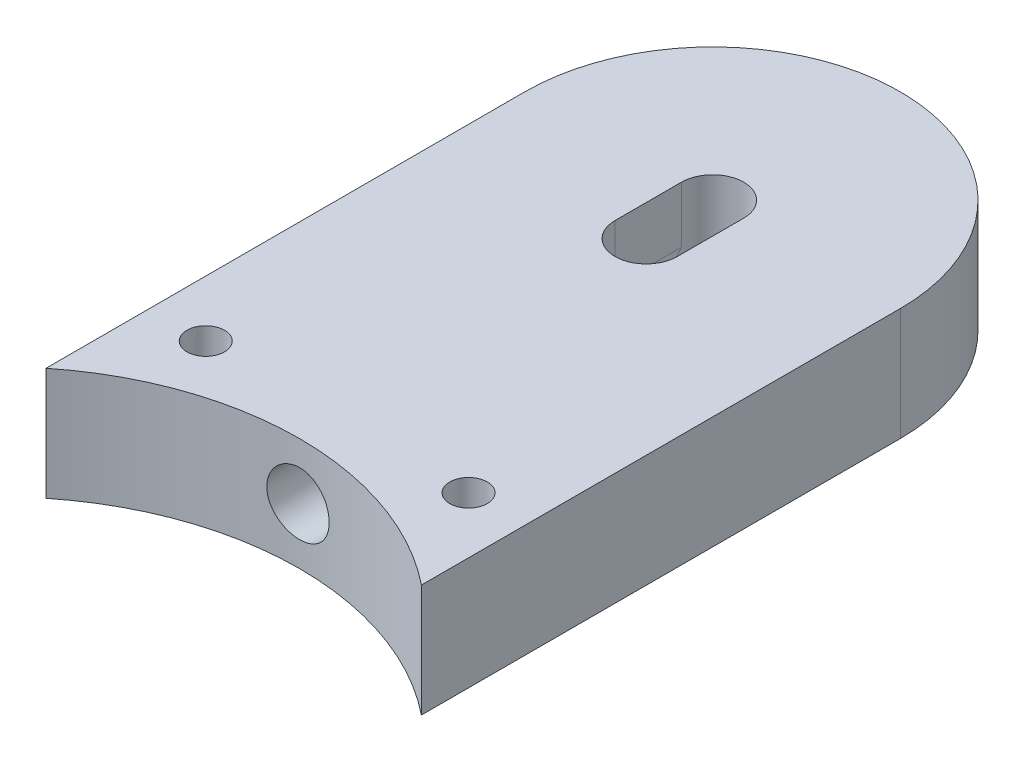
from build123d import *

# Parameters (mm, degrees)
ESQUISSE1_R                  = 4.15
BOSS_EXTRU_1_DEPTH           = 15
ENL_V_MAT_EXTRU_1_REACH      = 122
ENL_V_MAT_EXTRU_1_END_RADIUS = 4.15
ESQUISSE2_R                  = 4.15
ENL_V_MAT_EXTRU_2_DEPTH      = 7.5
TROU_TARAUD_M6X1_01_D        = 5


with BuildPart() as part:
    # Esquisse1 → Boss.-Extru.1 (new body)
    with BuildSketch(Plane(origin=(0, 0, 0), x_dir=(1, 0, 0), z_dir=(0, 1, 0))):
        with BuildLine():
            Line((25, 31.224989992), (25, 95))
            ThreePointArc((25, 95), (0, 120), (-25, 95))
            Line((-25, 95), (-25, 31.224989992))
            ThreePointArc((-25, 31.224989992), (0, 40), (25, 31.224989992))
        make_face()
        with Locations(Location((0, 95, 0), (0, 0, 270))):  # turned: the seam where the file's is
            Circle(ESQUISSE1_R, mode=Mode.SUBTRACT)
    extrude(amount=BOSS_EXTRU_1_DEPTH)

    # Enlèv. mat.-Extru.1: up to this cylinder (the profile starts outside it)
    enl_v_mat_extru_1_end = Plane(origin=(0, 7.5, -95), z_dir=(0, -1, 0)) * Cylinder(ENL_V_MAT_EXTRU_1_END_RADIUS, 253.3, mode=Mode.PRIVATE)
    # Esquisse2 → Enlèv. mat.-Extru.1 (cut, up to the surface)
    with BuildSketch(Plane.XY, mode=Mode.PRIVATE) as enl_v_mat_extru_1_sk1:
        with Locations((0, 7.5)):
            Circle(ESQUISSE2_R)
    enl_v_mat_extru_1_tool1 = extrude(enl_v_mat_extru_1_sk1.sketch, amount=-ENL_V_MAT_EXTRU_1_REACH, mode=Mode.PRIVATE) - enl_v_mat_extru_1_end
    add(enl_v_mat_extru_1_tool1.solids().sort_by_distance((0, 7.5, 0))[0], mode=Mode.SUBTRACT)

    # Esquisse3 → Enlèv. mat.-Extru.2 (cut)
    with BuildSketch(Plane(origin=(0, 15, 0), x_dir=(-1, 0, 0), z_dir=(0, 1, 0))):
        with BuildLine():
            Line((4.15, -95), (4.15, -86.15))
            ThreePointArc((4.15, -86.15), (0, -82), (-4.15, -86.15))
            Line((-4.15, -86.15), (-4.15, -95))
            ThreePointArc((-4.15, -95), (0, -99.15), (4.15, -95))
        make_face()
    extrude(amount=-ENL_V_MAT_EXTRU_2_DEPTH, mode=Mode.SUBTRACT)

    # Trou taraudé M6x1.01 (through all)
    with Locations(Plane.XZ):
        with Locations((17.5, -45), (-17.5, -45)):
            Hole(TROU_TARAUD_M6X1_01_D / 2)


solid = part.part
